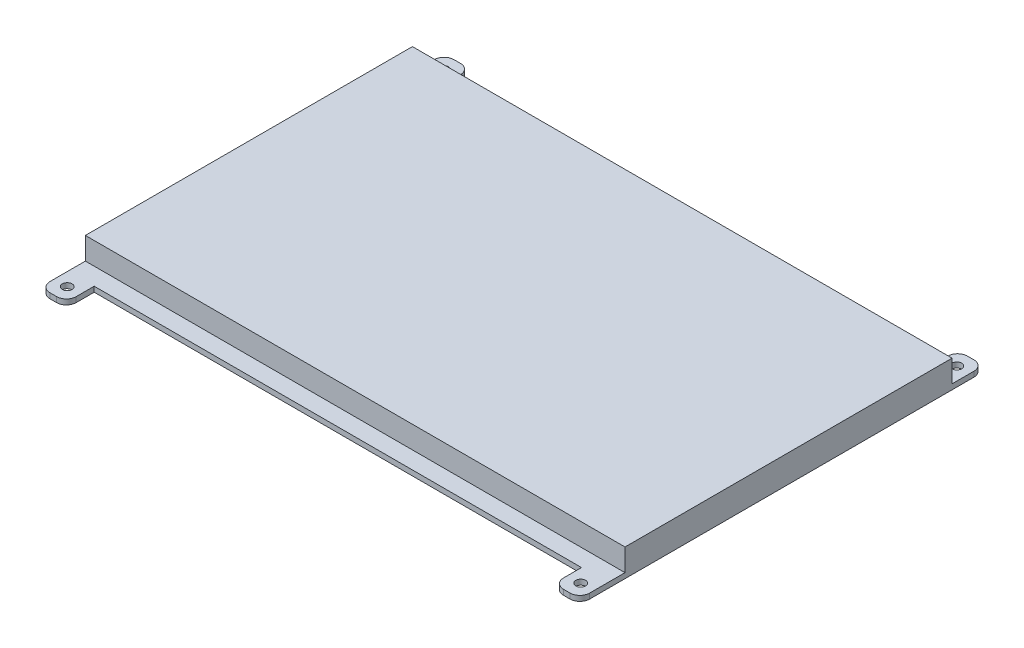
from build123d import *

# Parameters (mm, degrees)
CROQUIS1_R              = 1.5
SALIENTE_EXTRUIR1_DEPTH = 1.6
CROQUIS2_W              = 165
CROQUIS2_H              = 100
SALIENTE_EXTRUIR2_DEPTH = 6.8


with BuildPart() as part:
    # Croquis1 → Saliente-Extruir1 (new body)
    with BuildSketch(Plane(origin=(0, 0, 0), x_dir=(1, 0, 0), z_dir=(0, 1, 0))):
        with BuildLine():
            Line((82.5, -58.75), (82.5, 58.75))
            ThreePointArc((82.5, 58.75), (81.621320344, 60.871320344), (79.5, 61.75))
            Line((79.5, 61.75), (77.5, 61.75))
            ThreePointArc((77.5, 61.75), (75.378679656, 60.871320344), (74.5, 58.75))
            Line((74.5, 58.75), (74.5, 53.25))
            Line((74.5, 53.25), (-74.5, 53.25))
            Line((-74.5, 53.25), (-74.5, 58.75))
            ThreePointArc((-74.5, 58.75), (-75.378679656, 60.871320344), (-77.5, 61.75))
            Line((-77.5, 61.75), (-79.5, 61.75))
            ThreePointArc((-79.5, 61.75), (-81.621320344, 60.871320344), (-82.5, 58.75))
            Line((-82.5, 58.75), (-82.5, -58.75))
            ThreePointArc((-82.5, -58.75), (-81.621320344, -60.871320344), (-79.5, -61.75))
            Line((-79.5, -61.75), (-77.5, -61.75))
            ThreePointArc((-77.5, -61.75), (-75.378679656, -60.871320344), (-74.5, -58.75))
            Line((-74.5, -58.75), (-74.5, -53.25))
            Line((-74.5, -53.25), (74.5, -53.25))
            Line((74.5, -53.25), (74.5, -58.75))
            ThreePointArc((74.5, -58.75), (75.378679656, -60.871320344), (77.5, -61.75))
            Line((77.5, -61.75), (79.5, -61.75))
            ThreePointArc((79.5, -61.75), (81.621320344, -60.871320344), (82.5, -58.75))
        make_face()
        with Locations((78.5, 57.5)):
            Circle(CROQUIS1_R, mode=Mode.SUBTRACT)
        with Locations((78.5, -57.5)):
            Circle(CROQUIS1_R, mode=Mode.SUBTRACT)
        with Locations((-78.5, -57.5)):
            Circle(CROQUIS1_R, mode=Mode.SUBTRACT)
        with Locations((-78.5, 57.5)):
            Circle(CROQUIS1_R, mode=Mode.SUBTRACT)
    extrude(amount=SALIENTE_EXTRUIR1_DEPTH)

    # Croquis2 → Saliente-Extruir2 (add)
    with BuildSketch(Plane(origin=(0, 1.6, 0), x_dir=(1, 0, 0), z_dir=(0, 1, 0))):
        with Locations((0, 2.05)):
            Rectangle(CROQUIS2_W, CROQUIS2_H)
    extrude(amount=SALIENTE_EXTRUIR2_DEPTH)


solid = part.part
